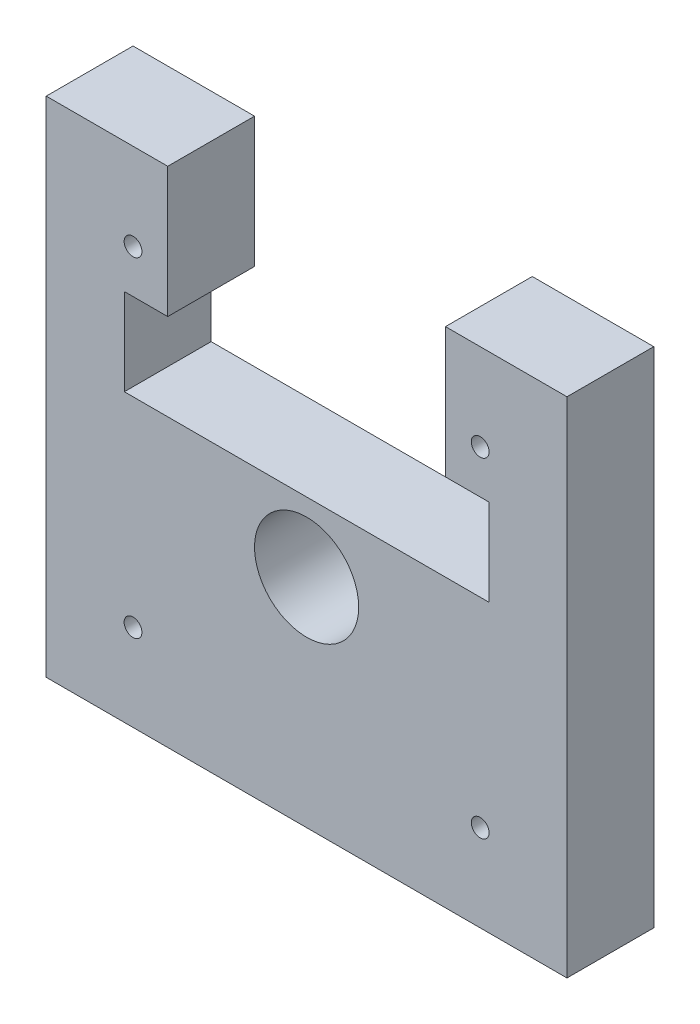
from build123d import *

# Parameters (mm, degrees)
SKETCH1_W                = 60
SKETCH1_H                = 58
SKETCH1_R                = 6
SKETCH1_W_2              = 42
SKETCH1_H_2              = 10
BOSS_EXTRUDE1_DEPTH      = 10
M2_5X0_45_TAPPED_HOLE1_D = 2.05
SKETCH4_W                = 32
SKETCH4_H                = 15
CUT_EXTRUDE1_DEPTH       = 11
CUT_EXTRUDE1_DEPTH_BACK  = 1


with BuildPart() as part:
    # Sketch1 → Boss-Extrude1 (new body)
    with BuildSketch(Plane.XY):
        with Locations((0, 4)):
            Rectangle(SKETCH1_W, SKETCH1_H)
        Circle(SKETCH1_R, mode=Mode.SUBTRACT)
        with Locations((0, 13)):
            Rectangle(SKETCH1_W_2, SKETCH1_H_2, mode=Mode.SUBTRACT)
        with Locations((0, 13)):
            Rectangle(SKETCH1_W_2, SKETCH1_H_2)
    extrude(amount=BOSS_EXTRUDE1_DEPTH)

    # M2.5x0.45 Tapped Hole1 (through all)
    with Locations(Plane.XY.offset(10)):
        with Locations((20, 23), (-20, 23), (-20, -15), (20, -15)):
            Hole(M2_5X0_45_TAPPED_HOLE1_D / 2)

    # Sketch4 → Cut-Extrude1 (cut, two sides)
    with BuildSketch(Plane.XY) as cut_extrude1_sk:
        with Locations((0, 25.5)):
            Rectangle(SKETCH4_W, SKETCH4_H)
        Polygon((16, 18), (-16, 18), (-21, 18), (-21, 8), (21, 8), (21, 18), align=None)
    extrude(amount=CUT_EXTRUDE1_DEPTH, mode=Mode.SUBTRACT)
    extrude(cut_extrude1_sk.sketch, amount=-CUT_EXTRUDE1_DEPTH_BACK, mode=Mode.SUBTRACT)


solid = part.part
